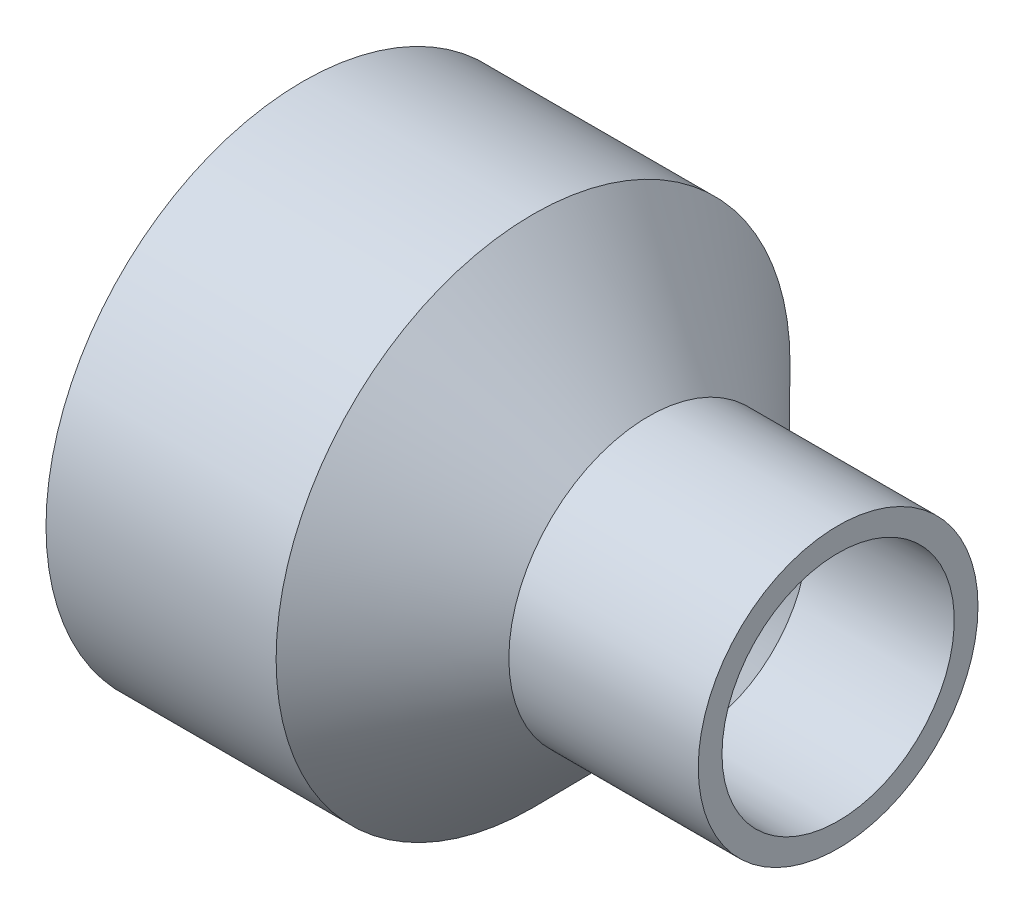
from build123d import *


with BuildPart() as part:
    # Sketch1 → Revolve1 (revolve)
    with BuildSketch(Plane.XY):
        Polygon((-13.49375, -57.0357), (15.827159161, -27.3558), (28.986069096, -27.3558), (31.75, -30.0863), (69.85, -30.3149), (69.85, -36.5125), (20.406922282, -36.5125), (-9.78282426, -67.071875), (-69.85, -67.071875), (-69.85, -57.3786), align=None)
    revolve(axis=Axis((-69.85, 0, 0), (1, 0, 0)))


solid = part.part
